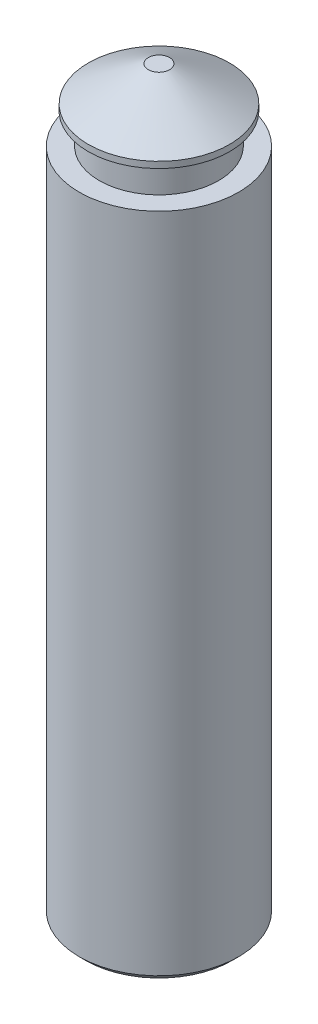
from build123d import *

# Parameters (mm, degrees)
SKETCH1_R           = 18.542
BOSS_EXTRUDE1_DEPTH = 155.575
SKETCH2_R           = 13.8811
BOSS_EXTRUDE2_DEPTH = 7.112
SKETCH3_R           = 16.4338
BOSS_EXTRUDE3_DEPTH = 9.525
CHAMFER1_SIZE       = 13.97
CHAMFER1_SIZE2      = 8.065583261
CHAMFER2_SIZE       = 1.524


with BuildPart() as part:
    # Sketch1 → Boss-Extrude1 (new body)
    with BuildSketch(Plane(origin=(0, 0, 0), x_dir=(1, 0, 0), z_dir=(0, 1, 0))):
        Circle(SKETCH1_R)
    extrude(amount=BOSS_EXTRUDE1_DEPTH)

    # Sketch2 → Boss-Extrude2 (add)
    with BuildSketch(Plane(origin=(0, 155.575, 0), x_dir=(1, 0, 0), z_dir=(0, 1, 0))):
        Circle(SKETCH2_R)
    extrude(amount=BOSS_EXTRUDE2_DEPTH)

    # Sketch3 → Boss-Extrude3 (add)
    with BuildSketch(Plane(origin=(0, 162.687, 0), x_dir=(1, 0, 0), z_dir=(0, 1, 0))):
        Circle(SKETCH3_R)
    extrude(amount=BOSS_EXTRUDE3_DEPTH)

    # Chamfer1
    chamfer1_edges = [part.edges().sort_by_distance(p)[0] for p in [
        (-16.4338, 172.212, 0),
    ]]
    chamfer1_side = [part.faces().sort_by_distance(p)[0] for p in [
        (0, 172.212, 0),
    ]]
    chamfer(chamfer1_edges, length=CHAMFER1_SIZE, length2=CHAMFER1_SIZE2, reference=chamfer1_side[0])

    # Chamfer2
    chamfer2_edges = [part.edges().sort_by_distance(p)[0] for p in [
        (-18.542, 0, 0),
    ]]
    chamfer(chamfer2_edges, length=CHAMFER2_SIZE)


solid = part.part
